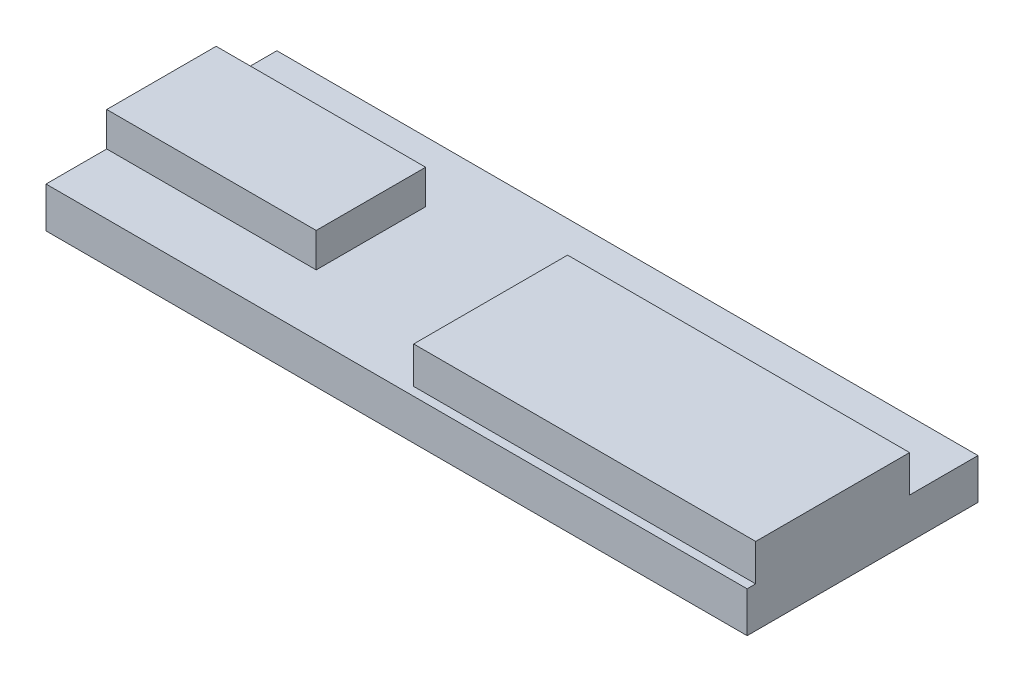
from build123d import *

# Parameters (mm, degrees)
SKETCH1_W           = 164
SKETCH1_H           = 54
BOSS_EXTRUDE1_DEPTH = 9.5
SKETCH3_W           = 49
SKETCH3_H           = 25.6
BOSS_EXTRUDE2_DEPTH = 8
SKETCH5_W           = 80
SKETCH5_H           = 36
BOSS_EXTRUDE3_DEPTH = 8.6


with BuildPart() as part:
    # Sketch1 → Boss-Extrude1 (new body)
    with BuildSketch(Plane(origin=(0, 0, 0), x_dir=(1, 0, 0), z_dir=(0, 1, 0))):
        with Locations((82, 27)):
            Rectangle(SKETCH1_W, SKETCH1_H)
    extrude(amount=BOSS_EXTRUDE1_DEPTH)

    # Sketch3 → Boss-Extrude2 (add)
    with BuildSketch(Plane(origin=(0, 9.5, 0), x_dir=(1, 0, 0), z_dir=(0, 1, 0))):
        with Locations((24.5, 27)):
            Rectangle(SKETCH3_W, SKETCH3_H)
    extrude(amount=BOSS_EXTRUDE2_DEPTH)

    # Sketch5 → Boss-Extrude3 (add)
    with BuildSketch(Plane(origin=(0, 9.5, 0), x_dir=(1, 0, 0), z_dir=(0, 1, 0))):
        with Locations((124, 20)):
            Rectangle(SKETCH5_W, SKETCH5_H)
    extrude(amount=BOSS_EXTRUDE3_DEPTH)


solid = part.part
